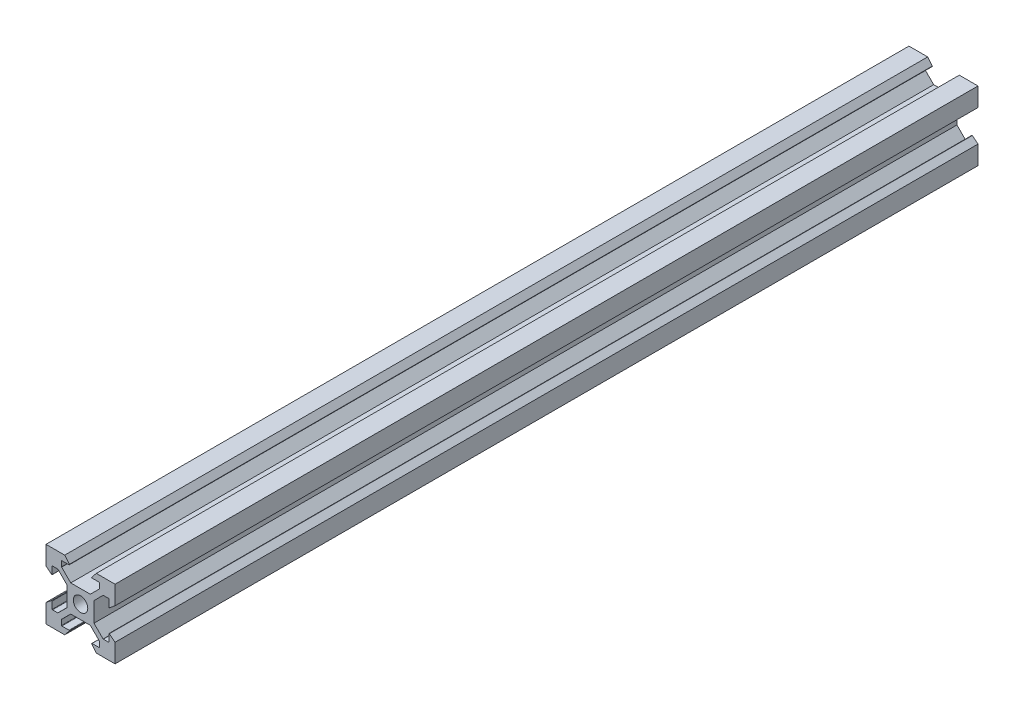
from build123d import *

# Parameters (mm, degrees)
SKETCH1_R           = 2.1
BOSS_EXTRUDE1_DEPTH = 250


with BuildPart() as part:
    # Sketch1 → Boss-Extrude1 (new body)
    with BuildSketch(Plane.XY):
        with BuildLine():
            Line((-2.839339828, 3.9), (-5.470710678, 6.53137085))
            ThreePointArc((-5.470710678, 6.53137085), (-5.492387953, 6.563813185), (-5.5, 6.602081528))
            Line((-5.5, 6.602081528), (-5.5, 8.1))
            ThreePointArc((-5.5, 8.1), (-5.470710678, 8.170710678), (-5.4, 8.2))
            Line((-5.4, 8.2), (-3.334418044, 8.2))
            ThreePointArc((-3.334418044, 8.2), (-3.244178397, 8.256909326), (-3.2566483, 8.362863876))
            Line((-3.2566483, 8.362863876), (-4.58, 10))
            Line((-4.58, 10), (-10, 10))
            Line((-10, 10), (-10, 4.58))
            Line((-10, 4.58), (-8.362863876, 3.2566483))
            ThreePointArc((-8.362863876, 3.2566483), (-8.256909326, 3.244178397), (-8.2, 3.334418044))
            Line((-8.2, 3.334418044), (-8.2, 5.4))
            ThreePointArc((-8.2, 5.4), (-8.170710678, 5.470710678), (-8.1, 5.5))
            Line((-8.1, 5.5), (-6.602081528, 5.5))
            ThreePointArc((-6.602081528, 5.5), (-6.563813185, 5.492387953), (-6.53137085, 5.470710678))
            Line((-6.53137085, 5.470710678), (-3.9, 2.839339828))
            Line((-3.9, 2.839339828), (-3.9, -2.839339828))
            Line((-3.9, -2.839339828), (-6.53137085, -5.470710678))
            ThreePointArc((-6.53137085, -5.470710678), (-6.563813185, -5.492387953), (-6.602081528, -5.5))
            Line((-6.602081528, -5.5), (-8.1, -5.5))
            ThreePointArc((-8.1, -5.5), (-8.170710678, -5.470710678), (-8.2, -5.4))
            Line((-8.2, -5.4), (-8.2, -3.334418044))
            ThreePointArc((-8.2, -3.334418044), (-8.256909326, -3.244178397), (-8.362863876, -3.2566483))
            Line((-8.362863876, -3.2566483), (-10, -4.58))
            Line((-10, -4.58), (-10, -10))
            Line((-10, -10), (-4.58, -10))
            Line((-4.58, -10), (-3.2566483, -8.362863876))
            ThreePointArc((-3.2566483, -8.362863876), (-3.244178397, -8.256909326), (-3.334418044, -8.2))
            Line((-3.334418044, -8.2), (-5.4, -8.2))
            ThreePointArc((-5.4, -8.2), (-5.470710678, -8.170710678), (-5.5, -8.1))
            Line((-5.5, -8.1), (-5.5, -6.602081528))
            ThreePointArc((-5.5, -6.602081528), (-5.492387953, -6.563813185), (-5.470710678, -6.53137085))
            Line((-5.470710678, -6.53137085), (-2.839339828, -3.9))
            Line((-2.839339828, -3.9), (2.839339828, -3.9))
            Line((2.839339828, -3.9), (5.470710678, -6.53137085))
            ThreePointArc((5.470710678, -6.53137085), (5.492387953, -6.563813185), (5.5, -6.602081528))
            Line((5.5, -6.602081528), (5.5, -8.1))
            ThreePointArc((5.5, -8.1), (5.470710678, -8.170710678), (5.4, -8.2))
            Line((5.4, -8.2), (3.334418044, -8.2))
            ThreePointArc((3.334418044, -8.2), (3.244178397, -8.256909326), (3.2566483, -8.362863876))
            Line((3.2566483, -8.362863876), (4.58, -10))
            Line((4.58, -10), (10, -10))
            Line((10, -10), (10, -4.58))
            Line((10, -4.58), (8.362863876, -3.2566483))
            ThreePointArc((8.362863876, -3.2566483), (8.256909326, -3.244178397), (8.2, -3.334418044))
            Line((8.2, -3.334418044), (8.2, -5.4))
            ThreePointArc((8.2, -5.4), (8.170710678, -5.470710678), (8.1, -5.5))
            Line((8.1, -5.5), (6.602081528, -5.5))
            ThreePointArc((6.602081528, -5.5), (6.563813185, -5.492387953), (6.53137085, -5.470710678))
            Line((6.53137085, -5.470710678), (3.9, -2.839339828))
            Line((3.9, -2.839339828), (3.9, 2.839339828))
            Line((3.9, 2.839339828), (6.53137085, 5.470710678))
            ThreePointArc((6.53137085, 5.470710678), (6.563813185, 5.492387953), (6.602081528, 5.5))
            Line((6.602081528, 5.5), (8.1, 5.5))
            ThreePointArc((8.1, 5.5), (8.170710678, 5.470710678), (8.2, 5.4))
            Line((8.2, 5.4), (8.2, 3.334418044))
            ThreePointArc((8.2, 3.334418044), (8.256909326, 3.244178397), (8.362863876, 3.2566483))
            Line((8.362863876, 3.2566483), (10, 4.58))
            Line((10, 4.58), (10, 10))
            Line((10, 10), (4.58, 10))
            Line((4.58, 10), (3.2566483, 8.362863876))
            ThreePointArc((3.2566483, 8.362863876), (3.244178397, 8.256909326), (3.334418044, 8.2))
            Line((3.334418044, 8.2), (5.4, 8.2))
            ThreePointArc((5.4, 8.2), (5.470710678, 8.170710678), (5.5, 8.1))
            Line((5.5, 8.1), (5.5, 6.602081528))
            ThreePointArc((5.5, 6.602081528), (5.492387953, 6.563813185), (5.470710678, 6.53137085))
            Line((5.470710678, 6.53137085), (2.839339828, 3.9))
            Line((2.839339828, 3.9), (-2.839339828, 3.9))
        make_face()
        Circle(SKETCH1_R, mode=Mode.SUBTRACT)
    extrude(amount=BOSS_EXTRUDE1_DEPTH)


solid = part.part
